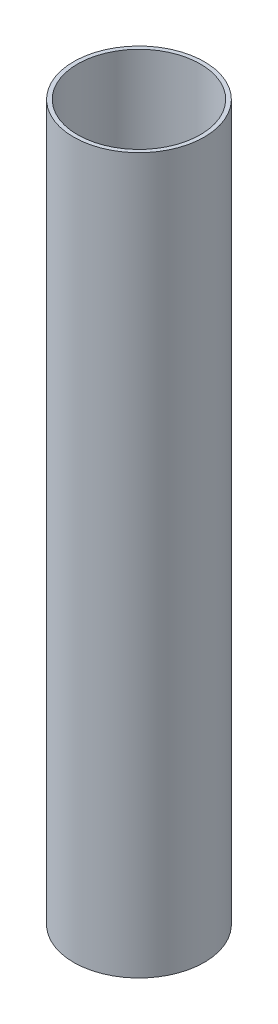
from build123d import *

# Parameters (mm, degrees)
SKETCH1_R           = 27
SKETCH1_R_2         = 25.35
BOSS_EXTRUDE1_DEPTH = 295.275


with BuildPart() as part:
    # Sketch1 → Boss-Extrude1 (new body)
    with BuildSketch(Plane(origin=(0, 0, 0), x_dir=(1, 0, 0), z_dir=(0, 1, 0))):
        Circle(SKETCH1_R)
        Circle(SKETCH1_R_2, mode=Mode.SUBTRACT)
    extrude(amount=BOSS_EXTRUDE1_DEPTH)


solid = part.part
